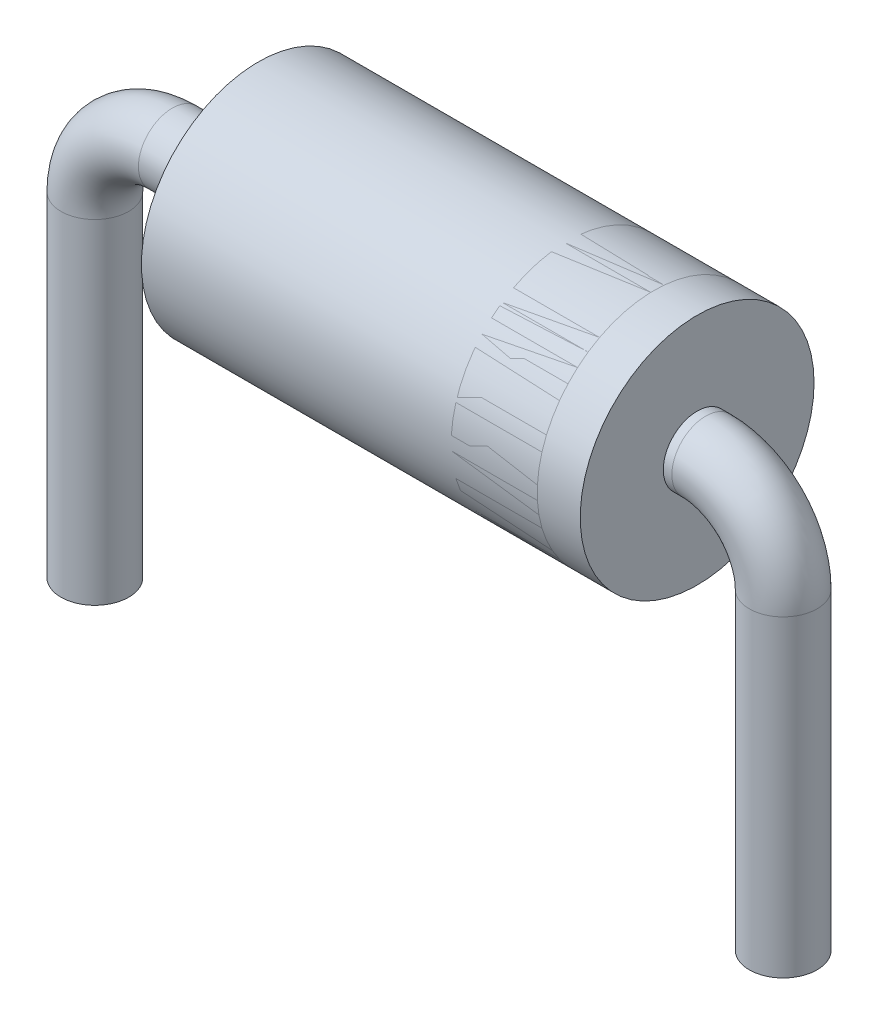
from build123d import *

# Parameters (mm, degrees)
SALIENTE_EXTRUIR1_DEPTH      = 0.5
SALIENTE_EXTRUIR1_DEPTH_BACK = 0.5
CROQUIS2_R                   = 1.3589
SALIENTE_EXTRUIR2_START      = 0.5
CROQUIS3_R                   = 1.3589
SALIENTE_EXTRUIR2_DEPTH      = 0.5
SALIENTE_EXTRUIR3_START      = 0.5
CROQUIS4_R                   = 1.3589
SALIENTE_EXTRUIR3_DEPTH      = 4.6
CROQUIS5_R                   = 0.3937
CROQUIS8_R                   = 0.3937


with BuildPart() as part:
    # Croquis2 → Saliente-Extruir1 (new, two sides: drawn at the far end of the back side and taken through both)
    with BuildSketch(Plane(origin=(0, 0, 0), x_dir=(0, 0, -1), z_dir=(1, 0, 0)).offset(-SALIENTE_EXTRUIR1_DEPTH_BACK)):
        Circle(CROQUIS2_R)
    extrude(amount=SALIENTE_EXTRUIR1_DEPTH + SALIENTE_EXTRUIR1_DEPTH_BACK)


with BuildPart() as body_2:
    # Croquis3 → Saliente-Extruir2 (new body)
    with BuildSketch(Plane(origin=(0, 0, 0), x_dir=(0, 0, -1), z_dir=(1, 0, 0)).offset(SALIENTE_EXTRUIR2_START)):
        Circle(CROQUIS3_R)
    extrude(amount=SALIENTE_EXTRUIR2_DEPTH)


with BuildPart() as body_3:
    # Croquis4 → Saliente-Extruir3 (new body)
    with BuildSketch(Plane(origin=(0, 0, 0), x_dir=(0, 0, -1), z_dir=(1, 0, 0)).offset(SALIENTE_EXTRUIR3_START)):
        Circle(CROQUIS4_R)
    extrude(amount=-SALIENTE_EXTRUIR3_DEPTH)


with BuildPart() as body_4:
    # Barrer1: sweep along a path in Croquis7
    with BuildLine(Plane.XY) as barrer1_path:
        Line((0, 0), (1.1, 0))
        ThreePointArc((1.1, 0), (1.736396103, -0.263603897), (2, -0.9))
        Line((2, -0.9), (2, -4.534050434))
    # Croquis5 → Barrer1 (sweep)
    with BuildSketch(Plane(origin=(0, 0, 0), x_dir=(0, 0, -1), z_dir=(1, 0, 0))):
        Circle(CROQUIS5_R)
    sweep(path=barrer1_path.line)


with BuildPart() as body_5:
    # Barrer2: sweep along a path in Croquis9
    with BuildLine(Plane.XY) as barrer2_path:
        Line((0, 0), (-5.1, 0))
        ThreePointArc((-5.1, 0), (-5.736396103, -0.263603897), (-6, -0.9))
        Line((-6, -0.9), (-6, -4.783473142))
    # Croquis8 → Barrer2 (sweep)
    with BuildSketch(Plane(origin=(0, 0, 0), x_dir=(0, 0, -1), z_dir=(1, 0, 0))):
        Circle(CROQUIS8_R)
    sweep(path=barrer2_path.line)


solid = Compound([part.part, body_2.part, body_3.part, body_4.part, body_5.part])
